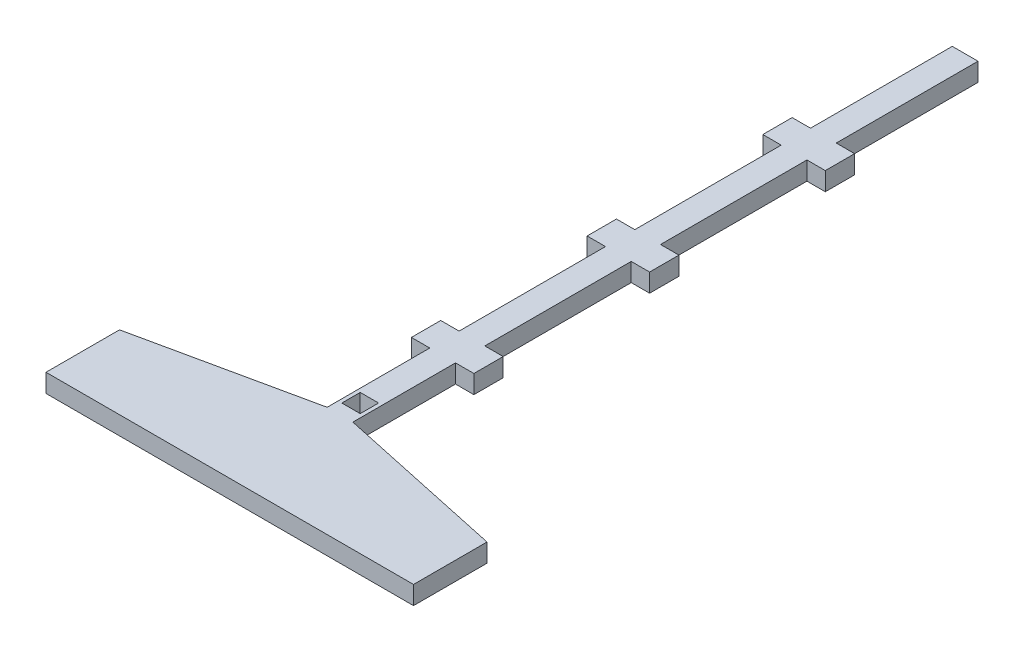
from build123d import *

# Parameters (mm, degrees)
SKETCH1_W           = 6.35
SKETCH1_H           = 6.35
BOSS_EXTRUDE2_DEPTH = 6.35


with BuildPart() as part:
    # Sketch1 → Boss-Extrude2 (new body)
    with BuildSketch(Plane(origin=(0, 0, 0), x_dir=(1, 0, 0), z_dir=(0, 1, 0))):
        Polygon((0, 0), (127, 0), (127, 25.4), (67.945, 38.1), (67.945, 73.566782), (74.295, 73.566782), (74.295, 83.698651246), (67.945, 83.698651246), (67.945, 134.288657), (74.295, 134.288657), (74.295, 144.420526246), (67.945, 144.420526246), (67.945, 195.010544446), (74.295, 195.010544446), (74.295, 205.142413692), (67.945, 205.142413692), (67.945, 254.126831852), (59.055, 254.126831852), (59.055, 205.142413692), (52.705, 205.142413692), (52.705, 195.010544446), (59.055, 195.010544446), (59.055, 144.420526246), (52.705, 144.420526246), (52.705, 134.288657), (59.055, 134.288657), (59.055, 83.698651246), (52.705, 83.698651246), (52.705, 73.566782), (59.055, 73.566782), (59.055, 38.1), (0, 25.4), align=None)
        with Locations((63.5, 45.085)):
            Rectangle(SKETCH1_W, SKETCH1_H, mode=Mode.SUBTRACT)
    extrude(amount=BOSS_EXTRUDE2_DEPTH)


solid = part.part
